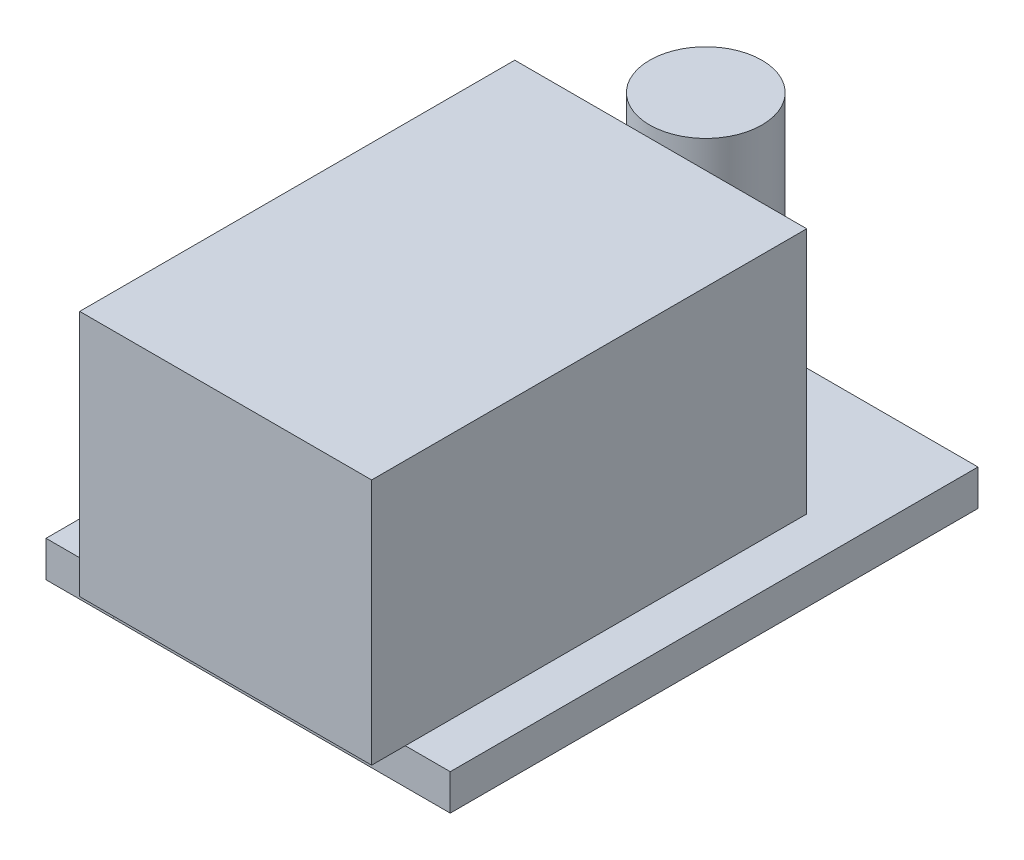
from build123d import *

# Parameters (mm, degrees)
SKETCH1_W             = 15
SKETCH1_H             = 23.5
BOSS_EXTRUDE1_DEPTH   = 1.6
SKETCH2_W             = 3
SKETCH2_H             = 4.5
BOSS_EXTRUDE2_DEPTH   = 1.6
SKETCH2_H_2           = 7.5
BOSS_EXTRUDE2_2_DEPTH = 1.6
SKETCH3_R             = 2.5
SKETCH3_W             = 13
SKETCH3_H             = 19.373569216
BOSS_EXTRUDE3_DEPTH   = 11


with BuildPart() as part:
    # Sketch1 → Boss-Extrude1 (new body)
    with BuildSketch(Plane(origin=(0, 0, 0), x_dir=(1, 0, 0), z_dir=(0, 1, 0))):
        Rectangle(SKETCH1_W, SKETCH1_H)
    extrude(amount=-BOSS_EXTRUDE1_DEPTH)

    # Sketch3 → Boss-Extrude3 (add)
    with BuildSketch(Plane(origin=(0, 0, 0), x_dir=(1, 0, 0), z_dir=(0, 1, 0))):
        with Locations((-1.997077294, 9.127185205)):
            Circle(SKETCH3_R)
        with Locations((-1, -3.563215392)):
            Rectangle(SKETCH3_W, SKETCH3_H)
    extrude(amount=BOSS_EXTRUDE3_DEPTH)


with BuildPart() as body_2:
    # Sketch2 → Boss-Extrude2 (new body)
    with BuildSketch(Plane(origin=(0, 0, 0), x_dir=(1, 0, 0), z_dir=(0, 1, 0))):
        with Locations((-9, 8.6)):
            Rectangle(SKETCH2_W, SKETCH2_H)
    extrude(amount=-BOSS_EXTRUDE2_DEPTH)


with BuildPart() as body_3:
    # Sketch2 → Boss-Extrude2 2 (new body)
    with BuildSketch(Plane(origin=(0, 0, 0), x_dir=(1, 0, 0), z_dir=(0, 1, 0))):
        with Locations((-9, -8)):
            Rectangle(SKETCH2_W, SKETCH2_H_2)
    extrude(amount=-BOSS_EXTRUDE2_2_DEPTH)


solid = Compound([part.part, body_2.part, body_3.part])
